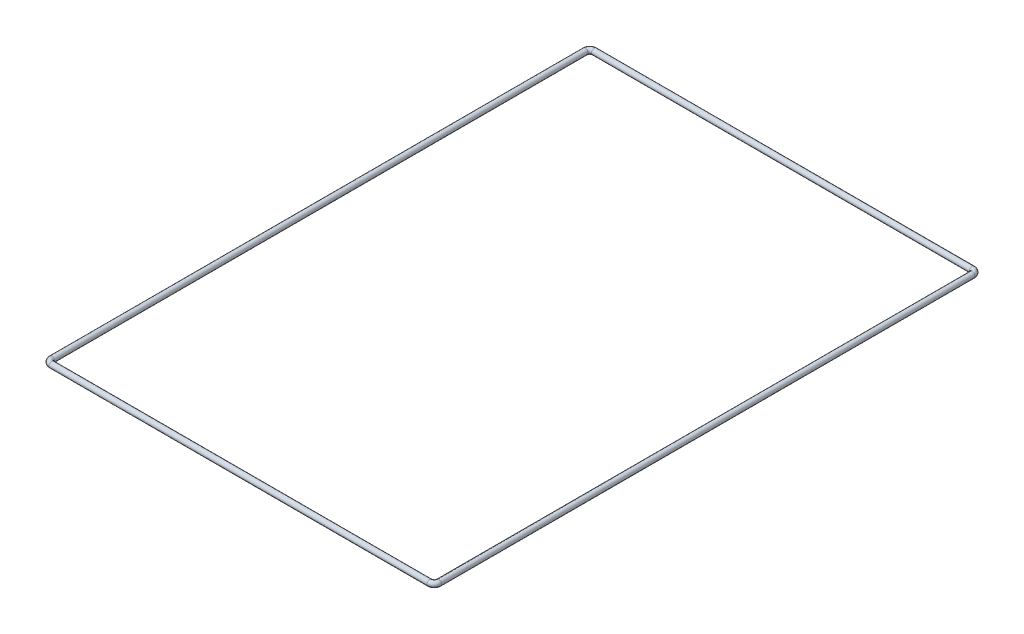
from build123d import *

# Parameters (mm, degrees)
SKETCH2_R   = 3.96875
SKETCH2_R_2 = 2.38125


with BuildPart() as part:
    # Sweep1: sweep along a curve in space
    with BuildLine() as sweep1_path:
        Line((0, 0, 591.762225459), (0, 0, -159.226874541))
        ThreePointArc((0, 0, -159.226874541), (1.859871939, 0, -163.717002602), (6.35, 0, -165.576874541))
        Line((6.35, 0, -165.576874541), (538.3657, 0, -165.576874541))
        ThreePointArc((538.3657, 0, -165.576874541), (542.855828061, 0, -163.717002602), (544.7157, 0, -159.226874541))
        Line((544.7157, 0, -159.226874541), (544.7157, 0, 591.762225459))
        ThreePointArc((544.7157, 0, 591.762225459), (542.855828061, 0, 596.252353519), (538.3657, 0, 598.112225459))
        Line((538.3657, 0, 598.112225459), (6.35, 0, 598.112225459))
        ThreePointArc((0, 0, 591.762225459), (1.859871939, 0, 596.252353519), (6.35, 0, 598.112225459))
    # Sketch2 → Sweep1 (sweep)
    with BuildSketch(Plane(origin=(0, 0, 591.762225459), x_dir=(-1, 0, 0), z_dir=(0, 0, -1))):
        Circle(SKETCH2_R)
        Circle(SKETCH2_R_2, mode=Mode.SUBTRACT)
    sweep(path=sweep1_path.line)


solid = part.part
